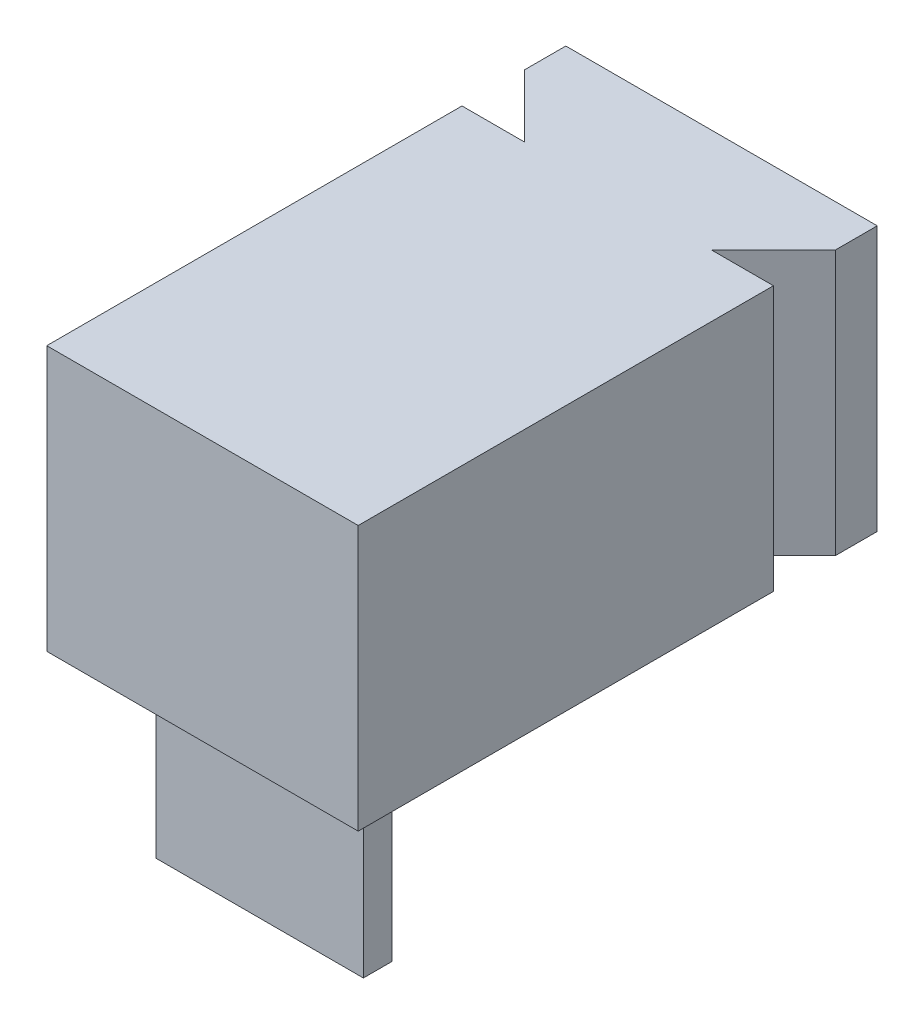
from build123d import *

# Parameters (mm, degrees)
SKETCH1_W           = 6
SKETCH1_H           = 8
BOSS_EXTRUDE1_DEPTH = 5.1
BOSS_EXTRUDE2_DEPTH = 5.1
SKETCH3_W           = 4
SKETCH3_H           = 0.55
BOSS_EXTRUDE3_DEPTH = 3.5


with BuildPart() as part:
    # Sketch1 → Boss-Extrude1 (new body)
    with BuildSketch(Plane(origin=(0, 0, 0), x_dir=(1, 0, 0), z_dir=(0, 1, 0))):
        Rectangle(SKETCH1_W, SKETCH1_H)
    extrude(amount=BOSS_EXTRUDE1_DEPTH)

    # Sketch2 → Boss-Extrude2 (add)
    with BuildSketch(Plane.XZ):
        Polygon((3, -6), (-3, -6), (-3, -5.2), (-1.8, -4), (1.8, -4), (3, -5.2), align=None)
    extrude(amount=-BOSS_EXTRUDE2_DEPTH)

    # Sketch3 → Boss-Extrude3 (add)
    with BuildSketch(Plane.XZ):
        with Locations((0, 2.625)):
            Rectangle(SKETCH3_W, SKETCH3_H)
    extrude(amount=BOSS_EXTRUDE3_DEPTH)


solid = part.part
